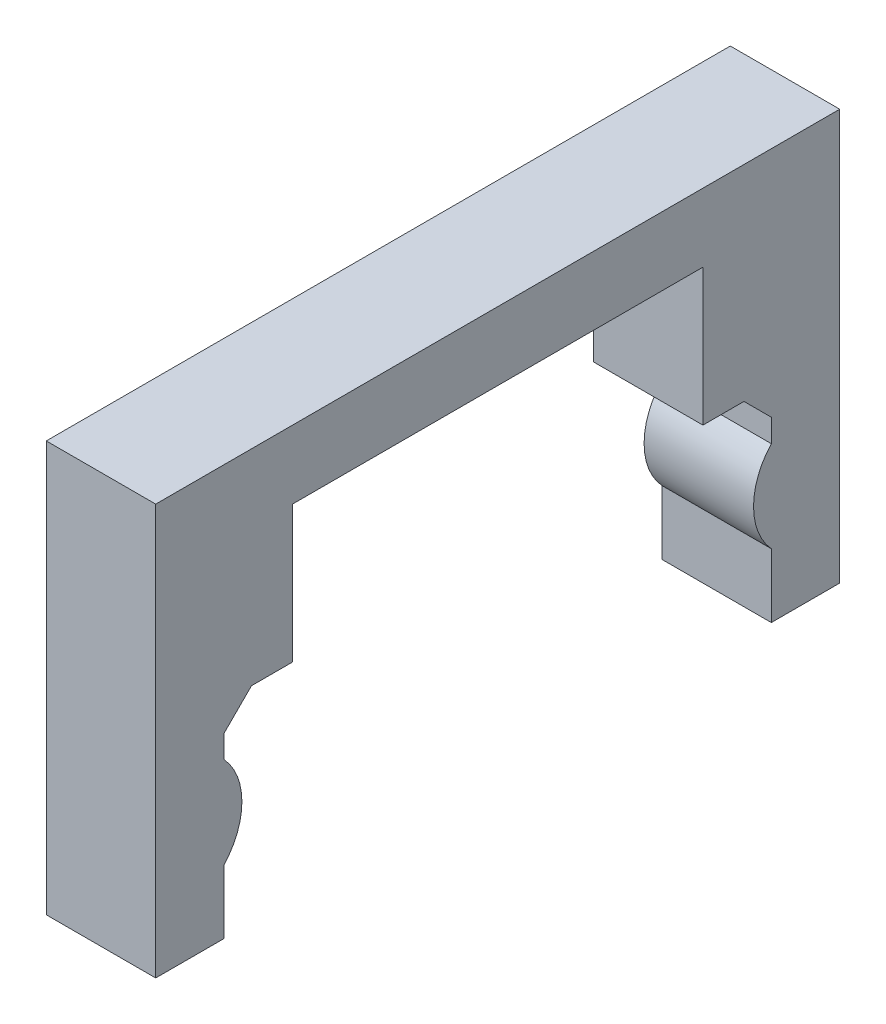
from build123d import *

# Parameters (mm, degrees)
BOSS_EXTRUDE1_DEPTH = 10.16
BOSS_EXTRUDE2_DEPTH = 10.16
CHAMFER1_SIZE       = 2.54


with BuildPart() as part:
    # Sketch3 → Boss-Extrude1 (new body)
    with BuildSketch(Plane(origin=(0, 0, 0), x_dir=(0, 0, -1), z_dir=(1, 0, 0))):
        Polygon((-101.845577666, -9.102652747), (-95.495577666, -9.102652747), (-95.495577666, 9.947347253), (-89.145577666, 9.947347253), (-89.145577666, 22.647347253), (-51.045577666, 22.647347253), (-51.045577666, 9.947347253), (-44.695577666, 9.947347253), (-44.695577666, -9.102652747), (-38.345577666, -9.102652747), (-38.345577666, 28.997347253), (-101.845577666, 28.997347253), align=None)
    extrude(amount=BOSS_EXTRUDE1_DEPTH)

    # Sketch4 → Boss-Extrude2 (add)
    with BuildSketch(Plane(origin=(10.16, 0, 0), x_dir=(0, 0, -1), z_dir=(1, 0, 0))):
        with BuildLine():
            Line((-101.845577666, -4.906246043), (-101.845577666, 7.020940549))
            ThreePointArc((-101.845577666, 7.020940549), (-93.844577666, 1.057347253), (-101.845577666, -4.906246043))
        make_face()
        with BuildLine():
            Line((-38.345577666, -4.906246043), (-38.345577666, 7.020940549))
            ThreePointArc((-38.345577666, 7.020940549), (-46.346577666, 1.057347253), (-38.345577666, -4.906246043))
        make_face()
    extrude(amount=-BOSS_EXTRUDE2_DEPTH)

    # Chamfer1
    chamfer1_edges = [part.edges().sort_by_distance(p)[0] for p in [
        (5.08, 9.947347253, 44.695577666),
        (5.08, 9.947347253, 95.495577666),
    ]]
    chamfer(chamfer1_edges, length=CHAMFER1_SIZE)


solid = part.part
